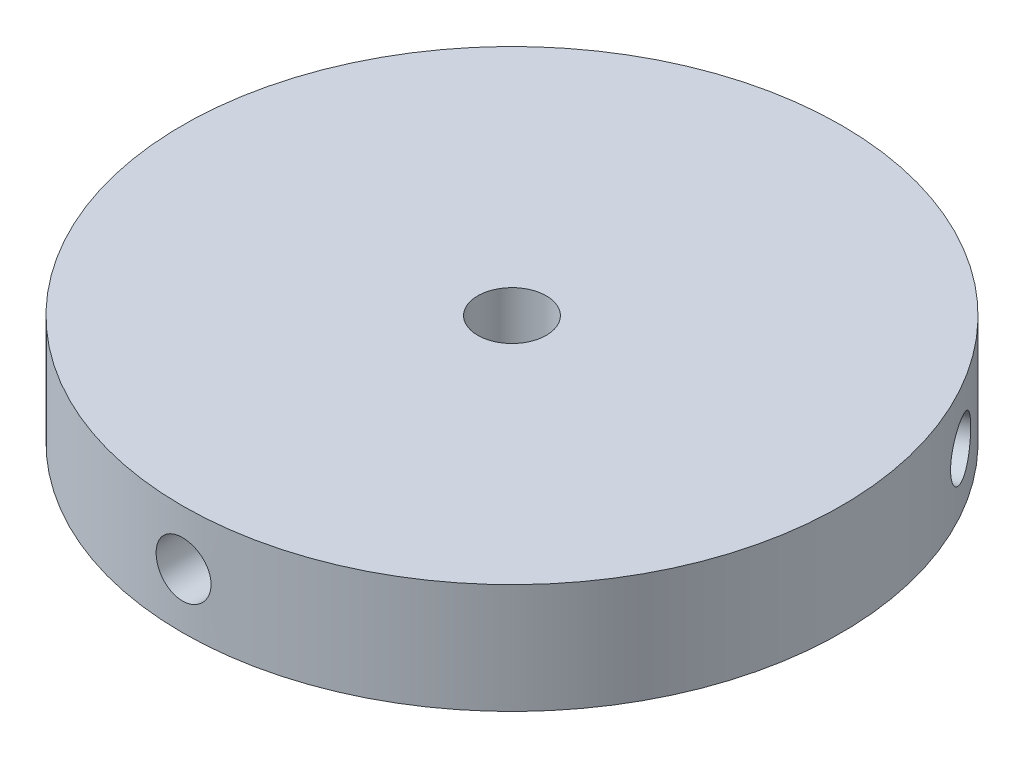
from build123d import *

# Parameters (mm, degrees)
SKETCH1_R           = 38.1
BOSS_EXTRUDE1_DEPTH = 12.7
SKETCH2_R           = 3.175
CUT_EXTRUDE1_DEPTH  = 9.525
CIRPATTERN1_COUNT   = 3
SKETCH3_R           = 3.9624
CUT_EXTRUDE2_DEPTH  = 12.7


with BuildPart() as part:
    # Sketch1 → Boss-Extrude1 (new body)
    with BuildSketch(Plane(origin=(0, 0, 0), x_dir=(1, 0, 0), z_dir=(0, 1, 0))):
        Circle(SKETCH1_R)
    extrude(amount=BOSS_EXTRUDE1_DEPTH)

    # Sketch2 → Cut-Extrude1 (cut)
    with BuildSketch(Plane.XY.offset(38.1)):
        with Locations((0, 6.35)):
            Circle(SKETCH2_R)
    cut_extrude1 = extrude(amount=-CUT_EXTRUDE1_DEPTH, mode=Mode.SUBTRACT)

    # CirPattern1: Cut-Extrude1 ×3 about axis
    cirpattern1_axis = Axis((0, 0, 0), (0, 1, 0))
    for i in range(1, CIRPATTERN1_COUNT):
        add(cut_extrude1.rotate(cirpattern1_axis, i * 360 / CIRPATTERN1_COUNT), mode=Mode.SUBTRACT)

    # Sketch3 → Cut-Extrude2 (cut)
    with BuildSketch(Plane(origin=(0, 12.7, 0), x_dir=(1, 0, 0), z_dir=(0, 1, 0))):
        Circle(SKETCH3_R)
    extrude(amount=-CUT_EXTRUDE2_DEPTH, mode=Mode.SUBTRACT)


solid = part.part
